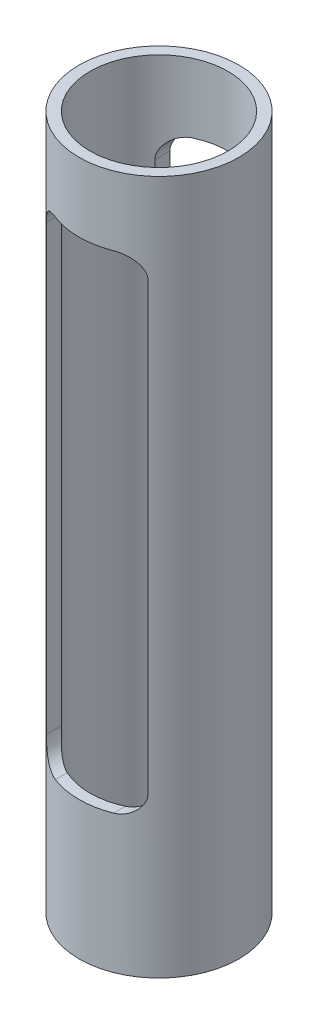
from build123d import *

# Parameters (mm, degrees)
SKETCH1_R               = 11
SKETCH1_R_2             = 9.5
BOSS_EXTRUDE1_DEPTH     = 95.5
CUT_EXTRUDE1_DEPTH      = 12
CUT_EXTRUDE1_DEPTH_BACK = 12


with BuildPart() as part:
    # Sketch1 → Boss-Extrude1 (new body)
    with BuildSketch(Plane(origin=(0, 0, 0), x_dir=(1, 0, 0), z_dir=(0, 1, 0))):
        Circle(SKETCH1_R)
        Circle(SKETCH1_R_2, mode=Mode.SUBTRACT)
    extrude(amount=BOSS_EXTRUDE1_DEPTH)

    # Sketch2 → Cut-Extrude1 (cut, two sides)
    with BuildSketch(Plane.XY) as cut_extrude1_sk:
        with BuildLine():
            ThreePointArc((-7, 83), (-6.121320344, 85.121320344), (-4, 86))
            Line((-4, 86), (4, 86))
            ThreePointArc((4, 86), (6.121320344, 85.121320344), (7, 83))
            Line((7, 83), (7, 22))
            ThreePointArc((7, 22), (6.121320344, 19.878679656), (4, 19))
            Line((4, 19), (-4, 19))
            ThreePointArc((-4, 19), (-6.121320344, 19.878679656), (-7, 22))
            Line((-7, 22), (-7, 83))
        make_face()
    extrude(amount=CUT_EXTRUDE1_DEPTH, mode=Mode.SUBTRACT)
    extrude(cut_extrude1_sk.sketch, amount=-CUT_EXTRUDE1_DEPTH_BACK, mode=Mode.SUBTRACT)


solid = part.part
